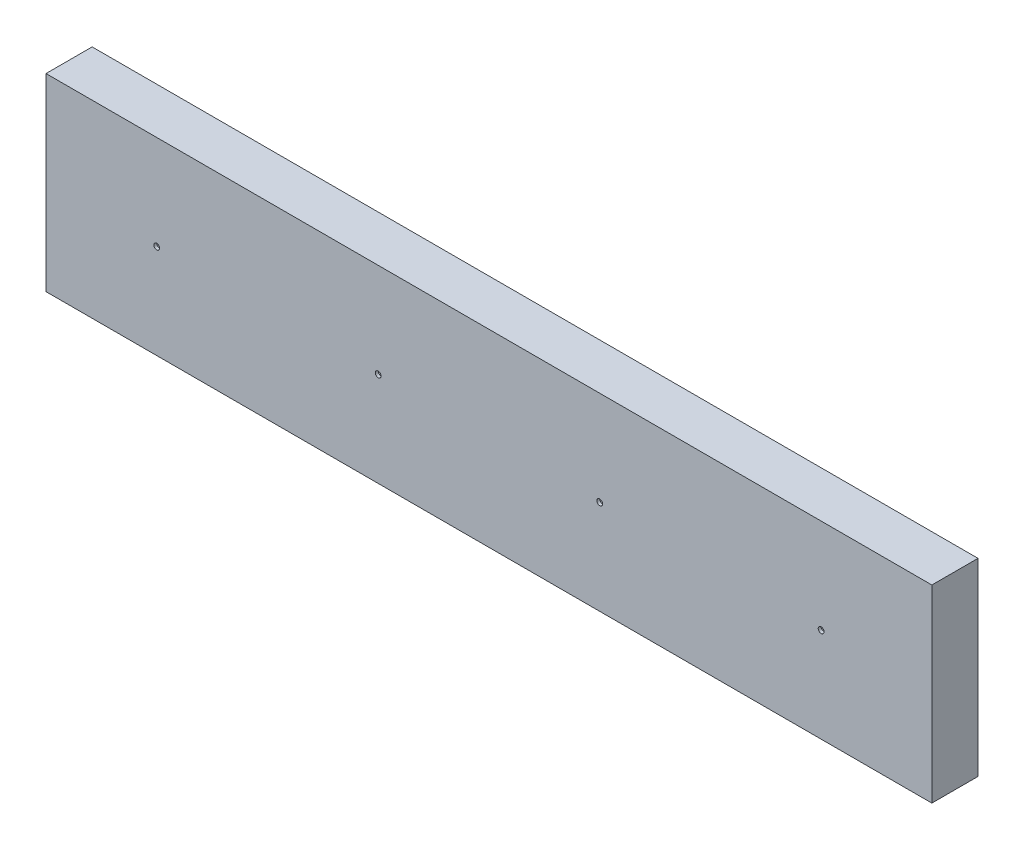
from build123d import *

# Parameters (mm, degrees)
SKETCH1_W               = 304.8
SKETCH1_H               = 65
BOSS_EXTRUDE1_DEPTH     = 15.875
SKETCH2_R               = 1
CUT_EXTRUDE1_DEPTH      = 1
CUT_EXTRUDE1_DEPTH_BACK = 1


with BuildPart() as part:
    # Sketch1 → Boss-Extrude1 (new body)
    with BuildSketch(Plane.XY):
        Rectangle(SKETCH1_W, SKETCH1_H)
    extrude(amount=BOSS_EXTRUDE1_DEPTH)

    # Sketch2 → Cut-Extrude1 (cut, two sides)
    with BuildSketch(Plane.XY.offset(15.875)) as cut_extrude1_sk:
        with Locations((-38.1, 0)):
            Circle(SKETCH2_R)
        with Locations((-114.3, 0)):
            Circle(SKETCH2_R)
        with Locations((114.3, 0)):
            Circle(SKETCH2_R)
        with Locations((38.1, 0)):
            Circle(SKETCH2_R)
    extrude(amount=CUT_EXTRUDE1_DEPTH, mode=Mode.SUBTRACT)
    extrude(cut_extrude1_sk.sketch, amount=-CUT_EXTRUDE1_DEPTH_BACK, mode=Mode.SUBTRACT)


solid = part.part
